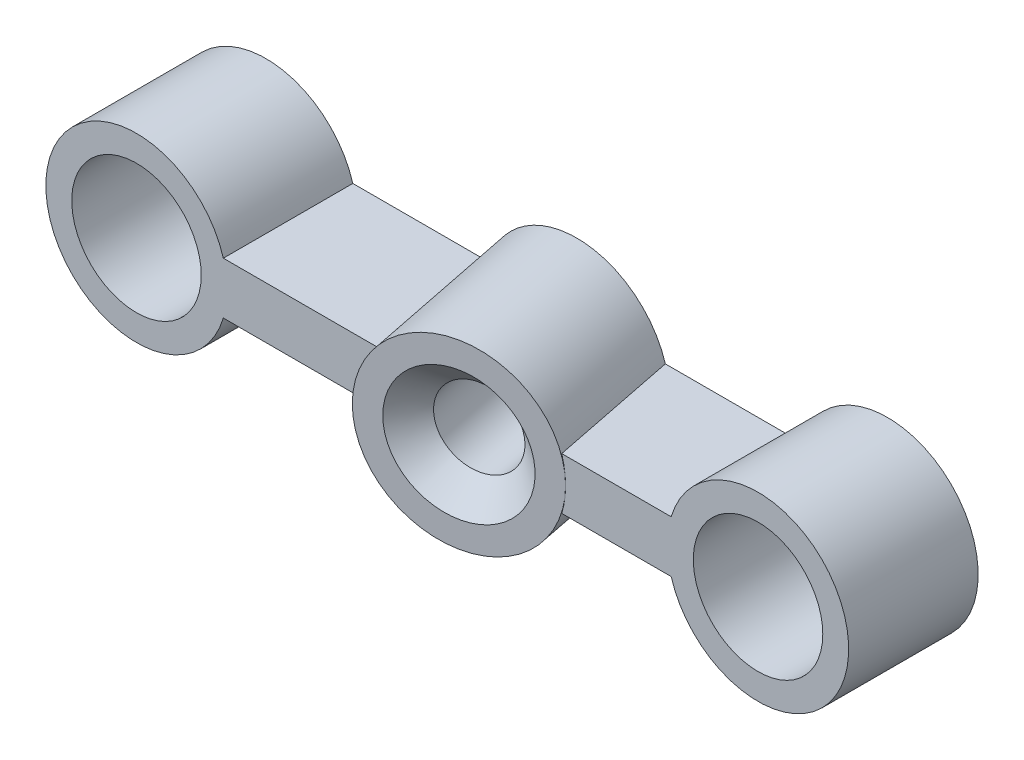
from build123d import *

# Parameters (mm, degrees)
SKETCH1_R               = 2.5
BOSS_EXTRUDE1_DEPTH     = 5
SKETCH4_R               = 1.5
CUT_EXTRUDE1_DEPTH      = 10.988857319
SKETCH5_W               = 10.682767576
SKETCH5_H               = 3.673973587
CUT_EXTRUDE2_DEPTH      = 4.5
CUT_EXTRUDE2_DEPTH_BACK = 4.5
CHAMFER1_SIZE           = 1


with BuildPart() as part:
    # Sketch1 → Boss-Extrude1 (new body)
    with BuildSketch(Plane.XY):
        with BuildLine():
            Line((-20.645898034, 1), (-3.354101966, 1))
            ThreePointArc((-3.354101966, 1), (3.5, 0), (-3.354101966, -1))
            Line((-3.354101966, -1), (-20.645898034, -1))
            ThreePointArc((-20.645898034, -1), (-27.5, 0), (-20.645898034, 1))
        make_face()
        Circle(SKETCH1_R, mode=Mode.SUBTRACT)
        with Locations((-24, 0)):
            Circle(SKETCH1_R, mode=Mode.SUBTRACT)
    extrude(amount=BOSS_EXTRUDE1_DEPTH)

    # Sketch3 → Revolve1 (revolve)
    with BuildSketch(Plane(origin=(0, 0, 0), x_dir=(1, 0, 0), z_dir=(0, 1, 0))):
        Polygon((-8.70524893, 1.372812946), (-7.43068634, -5), (-10.862718705, -5.686406473), (-12.137281295, 0.686406473), align=None)
    revolve(axis=Axis((-12.027607656, 0, -0.138038281), (0.196116135, 0, 0.980580676)))

    # Sketch4 → Cut-Extrude1 (cut, through all)
    with BuildSketch(Plane(origin=(-0.598819756, 0, -2.994098781), x_dir=(-0.980580676, 0, 0.196116135), z_dir=(-0.196116135, 0, -0.980580676))):
        with Locations((11.766968108, 0)):
            Circle(SKETCH4_R)
    extrude(amount=-CUT_EXTRUDE1_DEPTH, mode=Mode.SUBTRACT)

    # Sketch5 → Cut-Extrude2 (cut, two sides)
    with BuildSketch(Plane(origin=(0, 0, 0), x_dir=(1, 0, 0), z_dir=(0, 1, 0))) as cut_extrude2_sk:
        with Locations((-12.153708886, 1.836986794)):
            Rectangle(SKETCH5_W, SKETCH5_H)
    extrude(amount=CUT_EXTRUDE2_DEPTH, mode=Mode.SUBTRACT)
    extrude(cut_extrude2_sk.sketch, amount=-CUT_EXTRUDE2_DEPTH_BACK, mode=Mode.SUBTRACT)

    # Chamfer1
    chamfer1_edges = [part.edges().sort_by_distance(p)[0] for p in [
        (-9.391847692, 0, 5.39223227),
    ]]
    chamfer(chamfer1_edges, length=CHAMFER1_SIZE)


solid = part.part
